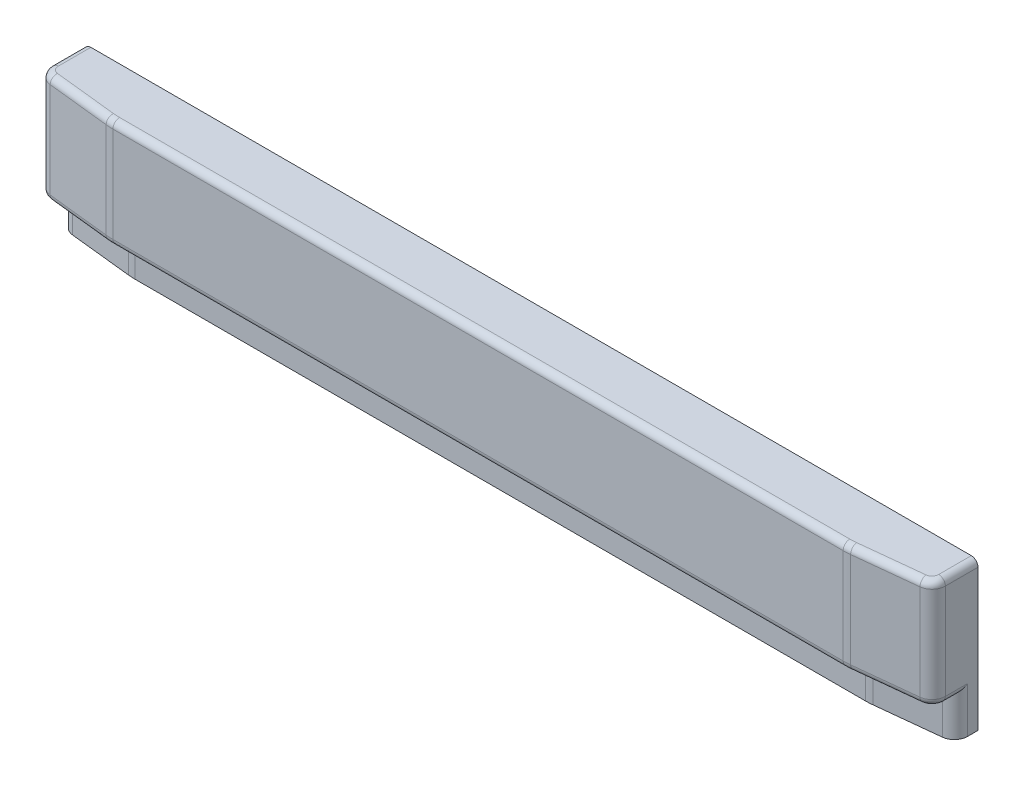
from build123d import *

# Parameters (mm, degrees)
BOSS_EXTRUDE1_DEPTH = 168.275
CUT_EXTRUDE1_DEPTH  = 44.45
FILLET1_R           = 15.24
FILLET2_R           = 76.2
FILLET3_R           = 7.62
FILLET4_R           = 7.62


with BuildPart() as part:
    # Sketch7 → Boss-Extrude1 (new body)
    with BuildSketch(Plane(origin=(0, 0, 0), x_dir=(1, 0, 0), z_dir=(0, 1, 0))):
        Polygon((0, 0), (1016, 0), (1016, -50.8), (927.1, -60.325), (88.9, -60.325), (0, -50.8), align=None)
    extrude(amount=BOSS_EXTRUDE1_DEPTH)

    # Sketch10 → Cut-Extrude1 (cut)
    with BuildSketch(Plane.XZ):
        Polygon((0, 50.8), (0, 25.4), (88.9, 34.925), (927.1, 34.925), (1016, 25.4), (1016, 50.8), (927.1, 60.325), (88.9, 60.325), align=None)
    extrude(amount=-CUT_EXTRUDE1_DEPTH, mode=Mode.SUBTRACT)

    # Fillet1
    fillet1_edges = [part.edges().sort_by_distance(p)[0] for p in [
        (1016, 106.3625, 50.8),
        (0, 106.3625, 50.8),
        (1016, 22.225, 25.4),
        (0, 22.225, 25.4),
    ]]
    fillet(fillet1_edges, radius=FILLET1_R)

    # Fillet2
    fillet2_edges = [part.edges().sort_by_distance(p)[0] for p in [
        (927.1, 106.3625, 60.325),
        (88.9, 106.3625, 60.325),
        (927.1, 22.225, 34.925),
        (88.9, 22.225, 34.925),
    ]]
    fillet(fillet2_edges, radius=FILLET2_R)

    # Fillet3
    fillet3_edges = [part.edges().sort_by_distance(p)[0] for p in [
        (1016, 168.275, 18.552816133),
        (0, 168.275, 18.552816133),
        (49.234552732, 168.275, 56.07513065),
        (3.904199904, 168.275, 47.291761863),
        (1012.095800096, 168.275, 47.291761863),
        (966.765447268, 168.275, 56.07513065),
        (508, 168.275, 60.325),
        (88.905795265, 168.275, 60.216512154),
        (927.094204735, 168.275, 60.216512154),
    ]]
    fillet(fillet3_edges, radius=FILLET3_R)

    # Fillet4
    fillet4_edges = [part.edges().sort_by_distance(p)[0] for p in [
        (1016, 44.45, 18.552816133),
        (0, 44.45, 18.552816133),
        (966.765447268, 44.45, 56.07513065),
        (3.904199904, 44.45, 47.291761863),
        (1012.095800096, 44.45, 47.291761863),
        (508, 44.45, 60.325),
        (49.234552732, 44.45, 56.07513065),
        (88.905795265, 44.45, 60.216512154),
        (927.094204735, 44.45, 60.216512154),
    ]]
    fillet(fillet4_edges, radius=FILLET4_R)


solid = part.part
